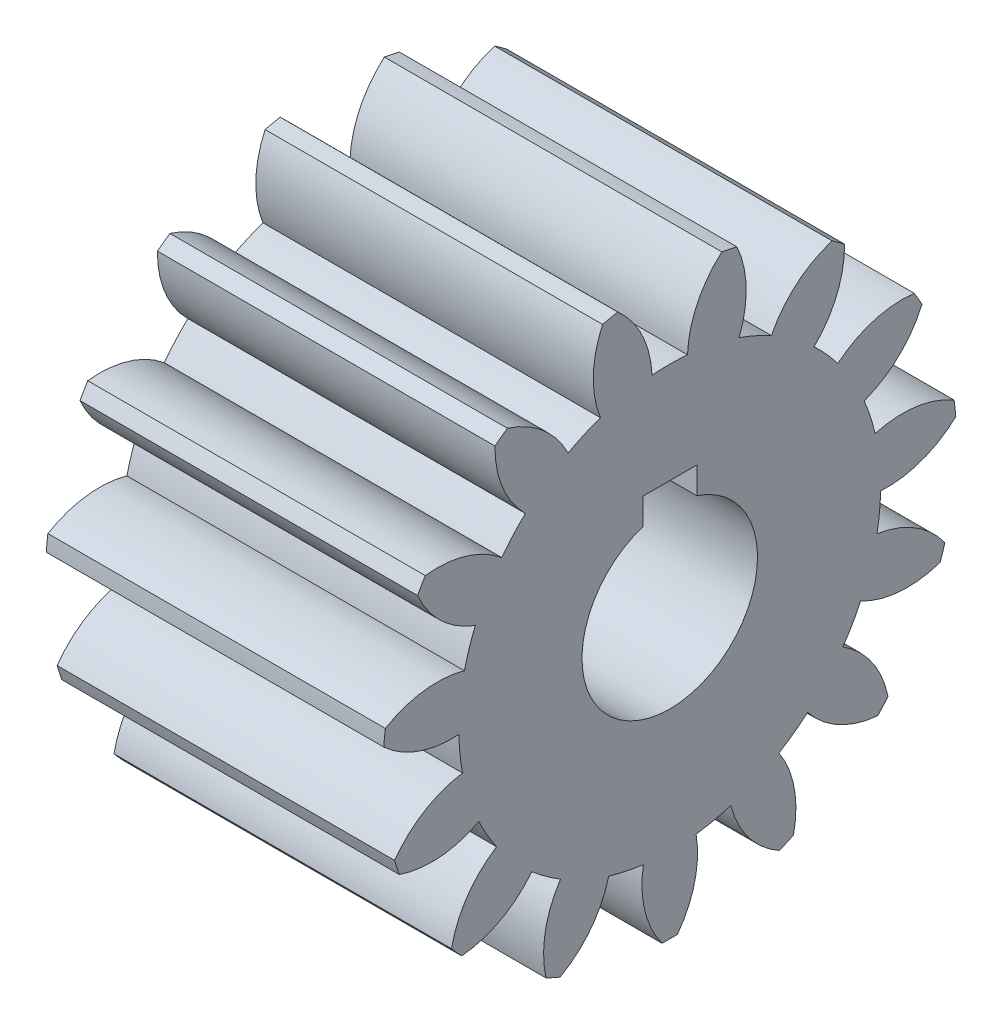
from build123d import *

# Parameters (mm, degrees)
BASPROSKE_W     = 50
BASPROSKE_H     = 42.5
TOOTHCUT_DEPTH  = 79.182478856
TEETHCUTS_COUNT = 15
TEETHCUTS_ANGLE = 336
BORSKE_R        = 13
BORE_DEPTH      = 50.0000508
KEYSKE_W        = 8
KEYSKE_H        = 16.3
KEYWAY_DEPTH    = 50.0000508


with BuildPart() as part:
    # BasProSke → Base-Revolve (revolve)
    with BuildSketch(Plane(origin=(0, 0, 0), x_dir=(1, 0, 0), z_dir=(0, 1, 0)), mode=Mode.PRIVATE) as base_revolve_sk:
        with Locations((25, 21.25)):
            Rectangle(BASPROSKE_W, BASPROSKE_H)
    revolve(base_revolve_sk.sketch.rotate(Axis((-10, 0, 0), (1, 0, 0)), 180), axis=Axis((-10, 0, 0), (1, 0, 0)))

    # TooCutSke → ToothCut (cut, through all)
    with BuildSketch(Plane(origin=(0, 0, 0), x_dir=(0, 0, -1), z_dir=(1, 0, 0))):
        with BuildLine():
            ThreePointArc((2.624472836, 31.138595719), (0, 31.249), (-2.624472836, 31.138595719))
            ThreePointArc((-2.624472836, 31.138595719), (-4.084227986, 37.002862003), (-7.739685892, 41.815151649))
            ThreePointArc((-7.739685892, 41.815151649), (0, 42.5254), (7.739685892, 41.815151649))
            ThreePointArc((7.739685892, 41.815151649), (4.084227986, 37.002862003), (2.624472836, 31.138595719))
        make_face()
    toothcut = extrude(amount=TOOTHCUT_DEPTH, mode=Mode.SUBTRACT)

    # TeethCuts: ToothCut ×15 about axis
    teethcuts_axis = Axis((-10, 0, 0), (1, 0, 0))
    for i in range(1, TEETHCUTS_COUNT):
        add(toothcut.rotate(teethcuts_axis, i * TEETHCUTS_ANGLE / (TEETHCUTS_COUNT - 1)), mode=Mode.SUBTRACT)

    # BorSke → Bore (cut, symmetric)
    with BuildSketch(Plane(origin=(0, 0, 0), x_dir=(0, 0, -1), z_dir=(1, 0, 0))):
        with Locations(Location((0, 0, 0), (0, 0, 180))):
            Circle(BORSKE_R)
    extrude(amount=BORE_DEPTH, both=True, mode=Mode.SUBTRACT)

    # KeySke → Keyway (cut, symmetric)
    with BuildSketch(Plane(origin=(0, 0, 0), x_dir=(0, 0, -1), z_dir=(1, 0, 0))):
        with Locations((0, 8.15)):
            Rectangle(KEYSKE_W, KEYSKE_H)
    extrude(amount=KEYWAY_DEPTH, both=True, mode=Mode.SUBTRACT)


solid = part.part
